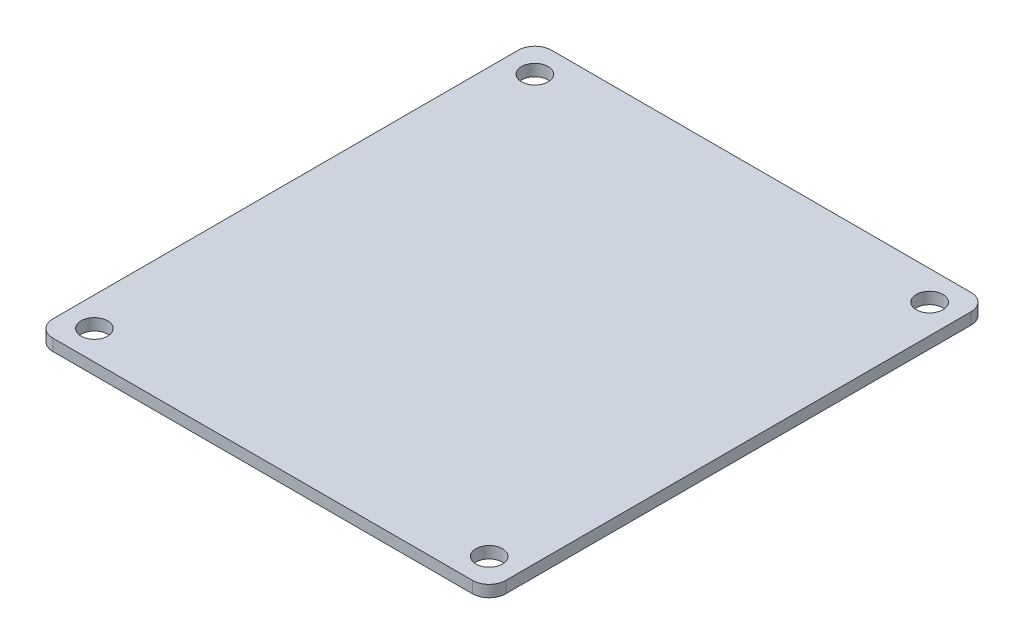
from build123d import *

# Parameters (mm, degrees)
SKETCH1_W           = 54.5
SKETCH1_H           = 60
BOSS_EXTRUDE1_DEPTH = 1.4
SKETCH2_R           = 1.6
CUT_EXTRUDE1_DEPTH  = 2.4
FILLET1_R           = 2


with BuildPart() as part:
    # Sketch1 → Boss-Extrude1 (new body)
    with BuildSketch(Plane(origin=(0, 0, 0), x_dir=(1, 0, 0), z_dir=(0, 1, 0))):
        Rectangle(SKETCH1_W, SKETCH1_H)
    extrude(amount=BOSS_EXTRUDE1_DEPTH)

    # Sketch2 → Cut-Extrude1 (cut, through all)
    with BuildSketch(Plane(origin=(0, 1.4, 0), x_dir=(1, 0, 0), z_dir=(0, 1, 0))):
        with Locations((-23.75, 26.5)):
            Circle(SKETCH2_R)
        with Locations((-23.75, -26.5)):
            Circle(SKETCH2_R)
        with Locations((23.75, -26.5)):
            Circle(SKETCH2_R)
        with Locations((23.75, 26.5)):
            Circle(SKETCH2_R)
    extrude(amount=-CUT_EXTRUDE1_DEPTH, mode=Mode.SUBTRACT)

    # Fillet1
    fillet1_edges = [part.edges().sort_by_distance(p)[0] for p in [
        (-27.25, 0.7, -30),
        (27.25, 0.7, -30),
        (27.25, 0.7, 30),
        (-27.25, 0.7, 30),
    ]]
    fillet(fillet1_edges, radius=FILLET1_R)


solid = part.part
